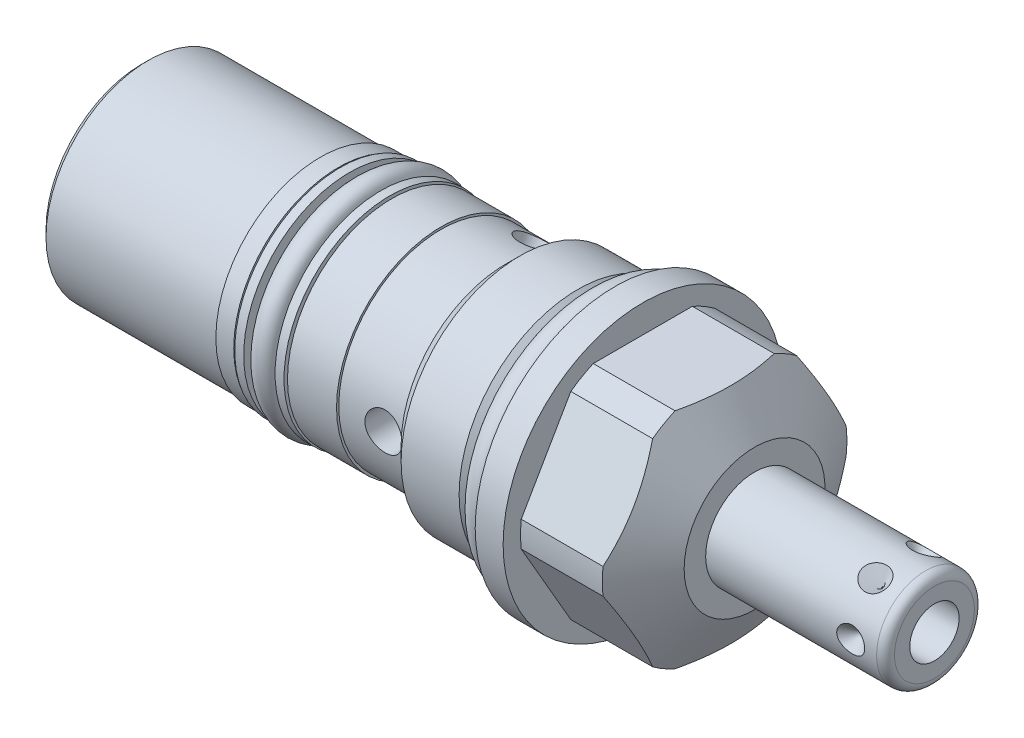
from build123d import *

# Parameters (mm, degrees)
SKETCH2_OUTSIDE_W  = 50.328
SKETCH2_OUTSIDE_H  = 50.328
CUT_EXTRUDE1_DEPTH = 12.7
CIRPATTERN1_COUNT  = 6
SKETCH6_W          = 13.716
SKETCH6_H          = 0.254
SKETCH7_R          = 0.8001
CUT_EXTRUDE2_DEPTH = 0.762
SKETCH8_W          = 6.1087
SKETCH8_H          = 2.0447
SKETCH9_W          = 1.016
SKETCH9_H          = 2.1844
SKETCH10_W         = 2.1082
SKETCH10_H         = 10.82675
CIRPATTERN2_COUNT  = 3
CHAMFER1_SIZE      = 0.762
SKETCH11_R         = 1.4732
SKETCH12_R         = 1.3081


with BuildPart() as part:
    # Sketch1 → Revolve1 (revolve)
    with BuildSketch(Plane.XY, mode=Mode.PRIVATE) as revolve1_sk:
        Polygon((0, 15.875), (3.175, 15.875), (3.175, 13.8938), (12.472790334, 13.8938), (15.875, 8.001), (15.875, 0), (-53.7972, 0), (-53.7972, 11.6205), (-12.4206, 11.6205), (-12.4206, 11.8745), (-10.80135, 13.49375), (-4.21005, 13.49375), (-2.7178, 12.0015), (0, 12.0015), align=None)
    revolve(revolve1_sk.sketch.rotate(Axis((0, 0, 0), (1, 0, 0)), 90), axis=Axis((0, 0, 0), (1, 0, 0)))  # turned: the seam where the file's is

    # Sketch2 outside → Cut-Extrude1 (cut)
    with BuildSketch(Plane(origin=(15.875, 0, 0), x_dir=(0, 0, -1), z_dir=(1, 0, 0))):
        Rectangle(SKETCH2_OUTSIDE_W, SKETCH2_OUTSIDE_H)
        Polygon((7.332348419, 12.7), (-7.332348419, 12.7), (-14.664696837, 0), (-7.332348419, -12.7), (7.332348419, -12.7), (14.664696837, 0), align=None, mode=Mode.SUBTRACT)
    extrude(amount=-CUT_EXTRUDE1_DEPTH, mode=Mode.SUBTRACT)

    # Sketch3 → Revolve2 (revolve)
    with BuildSketch(Plane.XY, mode=Mode.PRIVATE) as revolve2_sk:
        with BuildLine():
            Line((15.875, 5.55625), (35.306, 5.55625))
            ThreePointArc((35.306, 5.55625), (36.02442049, 5.25867049), (36.322, 4.54025))
            Line((36.322, 4.54025), (36.322, 0))
            Line((36.322, 0), (15.875, 0))
            Line((15.875, 0), (15.875, 5.55625))
        make_face()
    revolve(revolve2_sk.sketch.rotate(Axis((0, 0, 0), (1, 0, 0)), 90), axis=Axis((0, 0, 0), (1, 0, 0)))  # turned: the seam where the file's is

    # Sketch4 → Cut-Revolve1 (revolve, cut)
    with BuildSketch(Plane(origin=(0, 0, 0), x_dir=(1, 0, 0), z_dir=(0, 1, 0)), mode=Mode.PRIVATE) as cut_revolve1_sk:
        Polygon((33.9471, 5.55625), (32.3596, 5.55625), (32.3596, 3.96875), align=None)
    cut_revolve1 = revolve(cut_revolve1_sk.sketch.rotate(Axis((32.3596, 0, -10.073804773), (0, 0, 1)), 180), axis=Axis((32.3596, 0, -10.073804773), (0, 0, 1)), mode=Mode.SUBTRACT)  # turned: the seam where the file's is

    # CirPattern1: Cut-Revolve1 ×6 about axis
    cirpattern1_axis = Axis((0, 0, 0), (-1, 0, 0))
    for i in range(1, CIRPATTERN1_COUNT):
        add(cut_revolve1.rotate(cirpattern1_axis, i * 360 / CIRPATTERN1_COUNT), mode=Mode.SUBTRACT)

    # Sketch5 → Cut-Revolve2 (revolve, cut)
    with BuildSketch(Plane.XY, mode=Mode.PRIVATE) as cut_revolve2_sk:
        Polygon((36.322, 2.8067), (26.162, 2.8067), (24.475564501, 0), (36.322, 0), align=None)
    revolve(cut_revolve2_sk.sketch.rotate(Axis((0, 0, 0), (1, 0, 0)), 90), axis=Axis((0, 0, 0), (1, 0, 0)), mode=Mode.SUBTRACT)  # turned: the seam where the file's is

    # Sketch6 → Revolve3 (revolve)
    with BuildSketch(Plane.XY, mode=Mode.PRIVATE) as revolve3_sk:
        with Locations((-26.6192, 11.7475)):
            Rectangle(SKETCH6_W, SKETCH6_H)
    revolve(revolve3_sk.sketch.rotate(Axis((0, 0, 0), (-1, 0, 0)), 270), axis=Axis((0, 0, 0), (-1, 0, 0)))  # turned: the seam where the file's is

    # Sketch7 → Cut-Extrude2 (cut)
    with BuildSketch(Plane.ZY.offset(53.7972)):
        Circle(SKETCH7_R)
    extrude(amount=-CUT_EXTRUDE2_DEPTH, mode=Mode.SUBTRACT)

    # Sketch8 → Cut-Revolve3 (revolve, cut)
    with BuildSketch(Plane.XY, mode=Mode.PRIVATE) as cut_revolve3_sk:
        with Locations((-28.39085, 10.85215)):
            Rectangle(SKETCH8_W, SKETCH8_H)
    revolve(cut_revolve3_sk.sketch.rotate(Axis((0, 0, 0), (-1, 0, 0)), 270), axis=Axis((0, 0, 0), (-1, 0, 0)), mode=Mode.SUBTRACT)  # turned: the seam where the file's is

    # Sketch9 → Revolve4 (revolve)
    with BuildSketch(Plane.XY, mode=Mode.PRIVATE) as revolve4_sk:
        with Locations((-26.0985, 10.922)):
            Rectangle(SKETCH9_W, SKETCH9_H)
        with Locations((-30.6832, 10.922)):
            Rectangle(SKETCH9_W, SKETCH9_H)
    revolve(revolve4_sk.sketch.rotate(Axis((0, 0, 0), (-1, 0, 0)), 270), axis=Axis((0, 0, 0), (-1, 0, 0)))  # turned: the seam where the file's is

    # Sketch10 → Cut-Revolve4 (revolve, cut)
    with BuildSketch(Plane(origin=(0, 0, 0), x_dir=(1, 0, 0), z_dir=(0, 1, 0))):
        with Locations((-15.7353, -6.207125)):
            Rectangle(SKETCH10_W, SKETCH10_H)
    cut_revolve4 = revolve(axis=Axis((-14.6812, 0, -23.036850257), (0, 0, 1)), mode=Mode.SUBTRACT)

    # CirPattern2: Cut-Revolve4 ×3 about axis
    cirpattern2_axis = Axis((0, 0, 0), (1, 0, 0))
    for i in range(1, CIRPATTERN2_COUNT):
        add(cut_revolve4.rotate(cirpattern2_axis, i * 360 / CIRPATTERN2_COUNT), mode=Mode.SUBTRACT)

    # Chamfer1
    chamfer1_edges = [part.edges().sort_by_distance(p)[0] for p in [
        (-53.7972, 0, -11.6205),
    ]]
    chamfer(chamfer1_edges, length=CHAMFER1_SIZE)

    # Sketch13 → Cut-Revolve5 (revolve, cut)
    with BuildSketch(Plane.XY, mode=Mode.PRIVATE) as cut_revolve5_sk:
        Polygon((-53.7972, 4.572), (-51.7144, 4.129287193), (-51.039512807, 3.4544), (-42.0116, 3.4544), (-42.0116, 0), (-53.7972, 0), align=None)
    revolve(cut_revolve5_sk.sketch.rotate(Axis((-63.275446536, 0, 0), (1, 0, 0)), 90), axis=Axis((-63.275446536, 0, 0), (1, 0, 0)), mode=Mode.SUBTRACT)  # turned: the seam where the file's is


with BuildPart() as body_2:
    # Sketch11 → Revolve5 (revolve)
    with BuildSketch(Plane.XY, mode=Mode.PRIVATE) as revolve5_sk:
        with Locations((-1.4732, 13.4747)):
            Circle(SKETCH11_R)
    revolve(revolve5_sk.sketch.rotate(Axis((0, 0, 0), (1, 0, 0)), 90), axis=Axis((0, 0, 0), (1, 0, 0)))  # turned: the seam where the file's is


with BuildPart() as body_3:
    # Sketch12 → Revolve7 (revolve)
    with BuildSketch(Plane.XY, mode=Mode.PRIVATE) as revolve7_sk:
        with Locations((-28.39085, 11.1379)):
            Circle(SKETCH12_R)
    revolve(revolve7_sk.sketch.rotate(Axis((0, 0, 0), (-1, 0, 0)), 270), axis=Axis((0, 0, 0), (-1, 0, 0)))  # turned: the seam where the file's is


solid = Compound([part.part, body_2.part, body_3.part])
